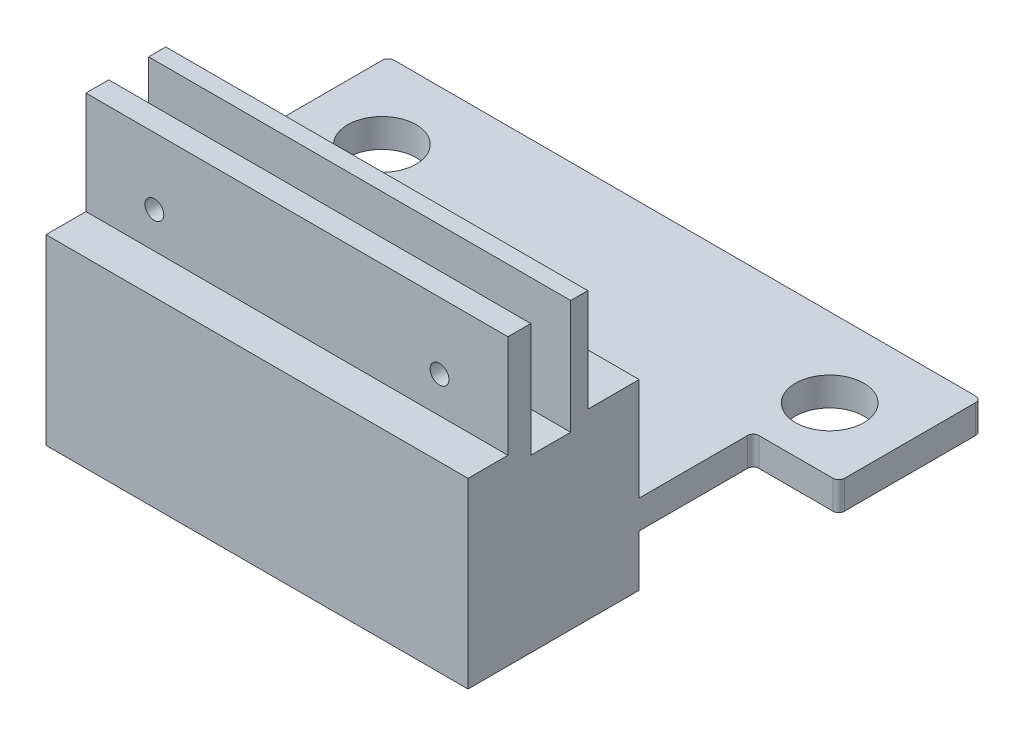
from build123d import *

# Parameters (mm, degrees)
SKETCH1_W           = 74
SKETCH1_H           = 50
BOSS_EXTRUDE1_DEPTH = 30
SKETCH2_R           = 10.5
CUT_EXTRUDE1_DEPTH  = 10
SKETCH3_R           = 6.25
CUT_EXTRUDE2_DEPTH  = 10
SKETCH4_W           = 7
SKETCH4_H           = 20
CUT_EXTRUDE3_DEPTH  = 111
SKETCH5_W           = 7
SKETCH5_H           = 18
SKETCH5_W_2         = 9
CUT_EXTRUDE4_DEPTH  = 111
SKETCH6_R           = 1.65
CUT_EXTRUDE5_DEPTH  = 111
SKETCH7_W           = 74
SKETCH7_H           = 5
BOSS_EXTRUDE2_DEPTH = 45
SKETCH8_W           = 25
SKETCH8_H           = 5
BOSS_EXTRUDE3_DEPTH = 15
SKETCH9_W           = 25
SKETCH9_H           = 5
BOSS_EXTRUDE4_DEPTH = 15
SKETCH10_R          = 6
CUT_EXTRUDE6_DEPTH  = 50
FILLET1_R           = 1


with BuildPart() as part:
    # Sketch1 → Boss-Extrude1 (new body)
    with BuildSketch(Plane.XY):
        with Locations((37, 25)):
            Rectangle(SKETCH1_W, SKETCH1_H)
    extrude(amount=BOSS_EXTRUDE1_DEPTH)

    # Sketch2 → Cut-Extrude1 (cut)
    with BuildSketch(Plane.XZ):
        with Locations((12.74, 15)):
            Circle(SKETCH2_R)
        with Locations((61.26167258, 15)):
            Circle(SKETCH2_R)
    extrude(amount=-CUT_EXTRUDE1_DEPTH, mode=Mode.SUBTRACT)

    # Sketch3 → Cut-Extrude2 (cut)
    with BuildSketch(Plane.XZ.offset(-10)):
        with Locations((12.74, 15)):
            Circle(SKETCH3_R)
        with Locations((61.26167258, 15)):
            Circle(SKETCH3_R)
    extrude(amount=-CUT_EXTRUDE2_DEPTH, mode=Mode.SUBTRACT)

    # Sketch4 → Cut-Extrude3 (cut)
    with BuildSketch(Plane.ZY):
        with Locations((15.5, 40)):
            Rectangle(SKETCH4_W, SKETCH4_H)
    extrude(amount=-CUT_EXTRUDE3_DEPTH, mode=Mode.SUBTRACT)

    # Sketch5 → Cut-Extrude4 (cut)
    with BuildSketch(Plane(origin=(74, 0, 0), x_dir=(0, 0, -1), z_dir=(1, 0, 0))):
        with Locations((-26.5, 41)):
            Rectangle(SKETCH5_W, SKETCH5_H)
        with Locations((-4.5, 41)):
            Rectangle(SKETCH5_W_2, SKETCH5_H)
    extrude(amount=-CUT_EXTRUDE4_DEPTH, mode=Mode.SUBTRACT)

    # Sketch6 → Cut-Extrude5 (cut)
    with BuildSketch(Plane(origin=(0, 0, 9), x_dir=(-1, 0, 0), z_dir=(0, 0, -1))):
        with Locations((-62, 38.308927031)):
            Circle(SKETCH6_R)
        with Locations((-12, 38.308927031)):
            Circle(SKETCH6_R)
    extrude(amount=-CUT_EXTRUDE5_DEPTH, mode=Mode.SUBTRACT)

    # Sketch7 → Boss-Extrude2 (add)
    with BuildSketch(Plane(origin=(0, 0, 0), x_dir=(-1, 0, 0), z_dir=(0, 0, -1))):
        with Locations((-37, 11.5)):
            Rectangle(SKETCH7_W, SKETCH7_H)
    extrude(amount=BOSS_EXTRUDE2_DEPTH)

    # Sketch8 → Boss-Extrude3 (add)
    with BuildSketch(Plane(origin=(74, 0, 0), x_dir=(0, 0, -1), z_dir=(1, 0, 0))):
        with Locations((32.5, 11.5)):
            Rectangle(SKETCH8_W, SKETCH8_H)
    extrude(amount=BOSS_EXTRUDE3_DEPTH)

    # Sketch9 → Boss-Extrude4 (add)
    with BuildSketch(Plane.ZY):
        with Locations((-32.5, 11.5)):
            Rectangle(SKETCH9_W, SKETCH9_H)
    extrude(amount=BOSS_EXTRUDE4_DEPTH)

    # Sketch10 → Cut-Extrude6 (cut)
    with BuildSketch(Plane.XZ):
        with Locations((-2.254021422, -31.146852886)):
            Circle(SKETCH10_R)
        with Locations((76.255693998, -31.146852886)):
            Circle(SKETCH10_R)
    extrude(amount=-CUT_EXTRUDE6_DEPTH, mode=Mode.SUBTRACT)

    # Fillet1
    fillet1_edges = [part.edges().sort_by_distance(p)[0] for p in [
        (74, 11.5, -20),
        (89, 11.5, -45),
        (89, 11.5, -20),
        (0, 11.5, -20),
        (-15, 11.5, -45),
        (-15, 11.5, -20),
    ]]
    fillet(fillet1_edges, radius=FILLET1_R)


solid = part.part
